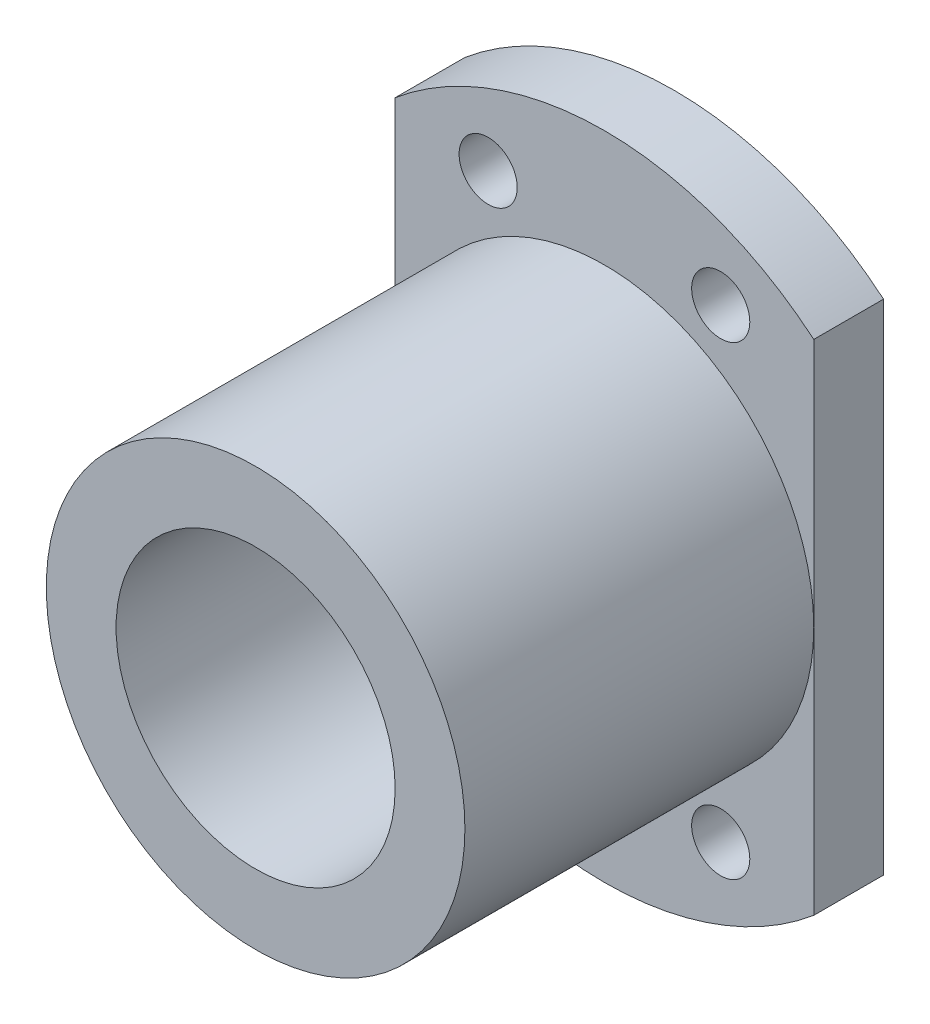
from build123d import *

# Parameters (mm, degrees)
SKETCH1_R               = 6
SKETCH1_R_2             = 1.25
BOSS_EXTRUDE1_DEPTH     = 3
SKETCH2_R               = 9
SKETCH2_R_2             = 6
LINEARBALLSUPPORT_DEPTH = 15


with BuildPart() as part:
    # Sketch1 → Boss-Extrude1 (new body)
    with BuildSketch(Plane.XY):
        with BuildLine():
            Line((-9, 10.723805295), (-9, -10.723805295))
            ThreePointArc((-9, -10.723805295), (0, -14), (9, -10.723805295))
            Line((9, -10.723805295), (9, 10.723805295))
            ThreePointArc((9, 10.723805295), (0, 14), (-9, 10.723805295))
        make_face()
        Circle(SKETCH1_R, mode=Mode.SUBTRACT)
        with Locations((-5, 10)):
            Circle(SKETCH1_R_2, mode=Mode.SUBTRACT)
        with Locations((5, 10)):
            Circle(SKETCH1_R_2, mode=Mode.SUBTRACT)
        with Locations((-5, -10)):
            Circle(SKETCH1_R_2, mode=Mode.SUBTRACT)
        with Locations((5, -10)):
            Circle(SKETCH1_R_2, mode=Mode.SUBTRACT)
    extrude(amount=BOSS_EXTRUDE1_DEPTH)

    # Sketch2 → LinearBallSupport (add)
    with BuildSketch(Plane.XY.offset(3)):
        Circle(SKETCH2_R)
        Circle(SKETCH2_R_2, mode=Mode.SUBTRACT)
    extrude(amount=LINEARBALLSUPPORT_DEPTH)


solid = part.part
